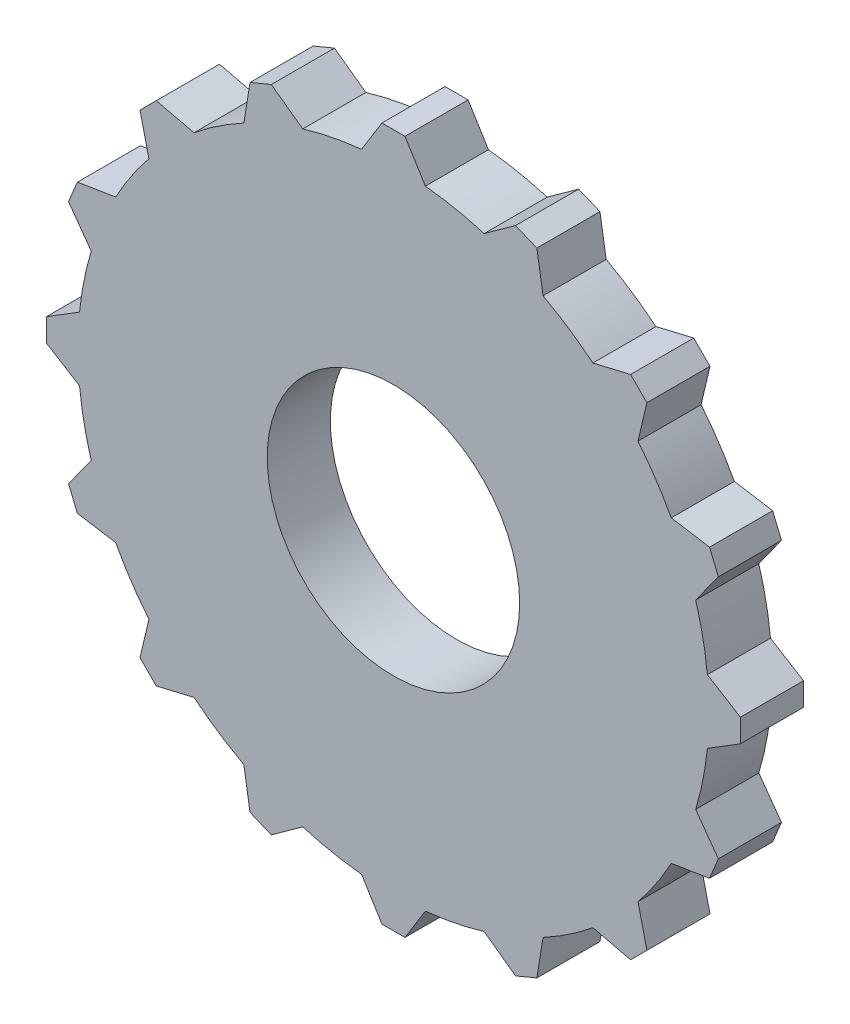
from build123d import *

# Parameters (mm, degrees)
SKETCH1_R           = 20
BOSS_EXTRUDE1_DEPTH = 10


with BuildPart() as part:
    # Sketch1 → Boss-Extrude1 (new body)
    with BuildSketch(Plane.XY):
        with BuildLine():
            Line((1.826311743, 54.969669686), (-1.826311743, 54.969669686))
            Line((-1.826311743, 54.969669686), (-5.055544828, 49.743758066))
            ThreePointArc((-5.055544828, 49.743758066), (-9.754516101, 49.03926402), (-14.365397683, 47.891913194))
            Line((-14.365397683, 47.891913194), (-19.348689832, 51.484251979))
            Line((-19.348689832, 51.484251979), (-22.723273911, 50.086453485))
            Line((-22.723273911, 50.086453485), (-23.706826468, 44.0225667))
            ThreePointArc((-23.706826468, 44.0225667), (-27.778511651, 41.573480615), (-31.599338619, 38.74895868))
            Line((-31.599338619, 38.74895868), (-37.578028776, 40.160823613))
            Line((-37.578028776, 40.160823613), (-40.160823613, 37.578028776))
            Line((-40.160823613, 37.578028776), (-38.74895868, 31.599338619))
            ThreePointArc((-38.74895868, 31.599338619), (-41.573480615, 27.778511651), (-44.0225667, 23.706826468))
            Line((-44.0225667, 23.706826468), (-50.086453485, 22.723273911))
            Line((-50.086453485, 22.723273911), (-51.484251979, 19.348689832))
            Line((-51.484251979, 19.348689832), (-47.891913194, 14.365397683))
            ThreePointArc((-47.891913194, 14.365397683), (-49.03926402, 9.754516101), (-49.743758066, 5.055544828))
            Line((-49.743758066, 5.055544828), (-54.969669686, 1.826311743))
            Line((-54.969669686, 1.826311743), (-54.969669686, -1.826311743))
            Line((-54.969669686, -1.826311743), (-49.743758066, -5.055544828))
            ThreePointArc((-49.743758066, -5.055544828), (-49.03926402, -9.754516101), (-47.891913194, -14.365397683))
            Line((-47.891913194, -14.365397683), (-51.484251979, -19.348689832))
            Line((-51.484251979, -19.348689832), (-50.086453485, -22.723273911))
            Line((-50.086453485, -22.723273911), (-44.0225667, -23.706826468))
            ThreePointArc((-44.0225667, -23.706826468), (-41.573480615, -27.778511651), (-38.74895868, -31.599338619))
            Line((-38.74895868, -31.599338619), (-40.160823613, -37.578028776))
            Line((-40.160823613, -37.578028776), (-37.578028776, -40.160823613))
            Line((-37.578028776, -40.160823613), (-31.599338619, -38.74895868))
            ThreePointArc((-31.599338619, -38.74895868), (-27.778511651, -41.573480615), (-23.706826468, -44.0225667))
            Line((-23.706826468, -44.0225667), (-22.723273911, -50.086453485))
            Line((-22.723273911, -50.086453485), (-19.348689832, -51.484251979))
            Line((-19.348689832, -51.484251979), (-14.365397683, -47.891913194))
            ThreePointArc((-14.365397683, -47.891913194), (-9.754516101, -49.03926402), (-5.055544828, -49.743758066))
            Line((-5.055544828, -49.743758066), (-1.826311743, -54.969669686))
            Line((-1.826311743, -54.969669686), (1.826311743, -54.969669686))
            Line((1.826311743, -54.969669686), (5.055544828, -49.743758066))
            ThreePointArc((5.055544828, -49.743758066), (9.754516101, -49.03926402), (14.365397683, -47.891913194))
            Line((14.365397683, -47.891913194), (19.348689832, -51.484251979))
            Line((19.348689832, -51.484251979), (22.723273911, -50.086453485))
            Line((22.723273911, -50.086453485), (23.706826468, -44.0225667))
            ThreePointArc((23.706826468, -44.0225667), (27.778511651, -41.573480615), (31.599338619, -38.74895868))
            Line((31.599338619, -38.74895868), (37.578028776, -40.160823613))
            Line((37.578028776, -40.160823613), (40.160823613, -37.578028776))
            Line((40.160823613, -37.578028776), (38.74895868, -31.599338619))
            ThreePointArc((38.74895868, -31.599338619), (41.573480615, -27.778511651), (44.0225667, -23.706826468))
            Line((44.0225667, -23.706826468), (50.086453485, -22.723273911))
            Line((50.086453485, -22.723273911), (51.484251979, -19.348689832))
            Line((51.484251979, -19.348689832), (47.891913194, -14.365397683))
            ThreePointArc((47.891913194, -14.365397683), (49.03926402, -9.754516101), (49.743758066, -5.055544828))
            Line((49.743758066, -5.055544828), (54.969669686, -1.826311743))
            Line((54.969669686, -1.826311743), (54.969669686, 1.826311743))
            Line((54.969669686, 1.826311743), (49.743758066, 5.055544828))
            ThreePointArc((49.743758066, 5.055544828), (49.03926402, 9.754516101), (47.891913194, 14.365397683))
            Line((47.891913194, 14.365397683), (51.484251979, 19.348689832))
            Line((51.484251979, 19.348689832), (50.086453485, 22.723273911))
            Line((50.086453485, 22.723273911), (44.0225667, 23.706826468))
            ThreePointArc((44.0225667, 23.706826468), (41.573480615, 27.778511651), (38.74895868, 31.599338619))
            Line((38.74895868, 31.599338619), (40.160823613, 37.578028776))
            Line((40.160823613, 37.578028776), (37.578028776, 40.160823613))
            Line((37.578028776, 40.160823613), (31.599338619, 38.74895868))
            ThreePointArc((31.599338619, 38.74895868), (27.778511651, 41.573480615), (23.706826468, 44.0225667))
            Line((23.706826468, 44.0225667), (22.723273911, 50.086453485))
            Line((22.723273911, 50.086453485), (19.348689832, 51.484251979))
            Line((19.348689832, 51.484251979), (14.365397683, 47.891913194))
            ThreePointArc((14.365397683, 47.891913194), (9.754516101, 49.03926402), (5.055544828, 49.743758066))
            Line((5.055544828, 49.743758066), (1.826311743, 54.969669686))
        make_face()
        Circle(SKETCH1_R, mode=Mode.SUBTRACT)
    extrude(amount=BOSS_EXTRUDE1_DEPTH)


solid = part.part
